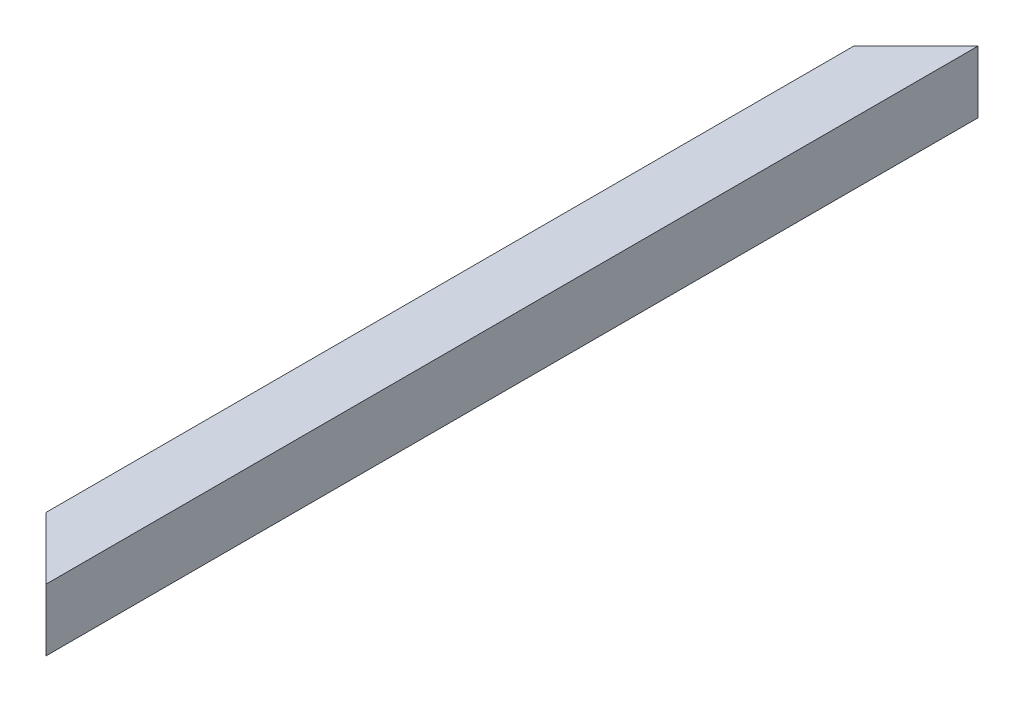
from build123d import *

# Parameters (mm, degrees)
SKETCH1_W          = 60
SKETCH1_H          = 60
SKETCH1_W_2        = 52
SKETCH1_H_2        = 52
CUT_EXTRUDE1_DEPTH = 61.0000001


with BuildPart() as part:
    # Sweep1: sweep along a curve in space
    with BuildLine() as sweep1_path:
        add(Edge.make_bspline(
            [(0, 0, 0), (0, 0, 900)],
            knots=[0, 0, 1, 1], degree=1))
    # Sketch1 → Sweep1 (sweep)
    with BuildSketch(Plane.XY):
        Rectangle(SKETCH1_W, SKETCH1_H)
        Rectangle(SKETCH1_W_2, SKETCH1_H_2, mode=Mode.SUBTRACT)
    sweep(path=sweep1_path.line)

    # Sketch2 → Cut-Extrude1 (cut, through all)
    with BuildSketch(Plane(origin=(0, 30, 0), x_dir=(1, 0, 0), z_dir=(0, 1, 0))):
        Polygon((30, 0), (-30, -60), (-30, 0), align=None)
        Polygon((30, -900), (-30, -840), (-30, -900), align=None)
    extrude(amount=-CUT_EXTRUDE1_DEPTH, mode=Mode.SUBTRACT)


solid = part.part
